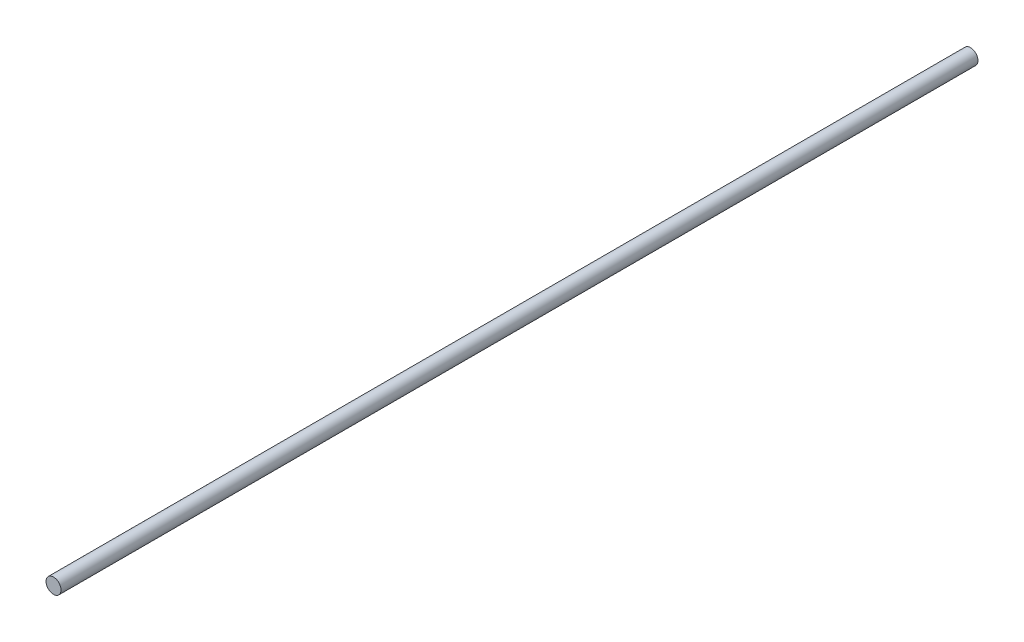
from build123d import *

# Parameters (mm, degrees)
SKETCH3_R                = 2.5
BOSS_EXTRUDE1_DEPTH      = 152.4
BOSS_EXTRUDE1_DEPTH_BACK = 152.4


with BuildPart() as part:
    # Sketch3 → Boss-Extrude1 (new body, two sides)
    with BuildSketch(Plane.XY) as boss_extrude1_sk:
        Circle(SKETCH3_R)
    extrude(amount=BOSS_EXTRUDE1_DEPTH)
    extrude(boss_extrude1_sk.sketch, amount=-BOSS_EXTRUDE1_DEPTH_BACK)


solid = part.part
